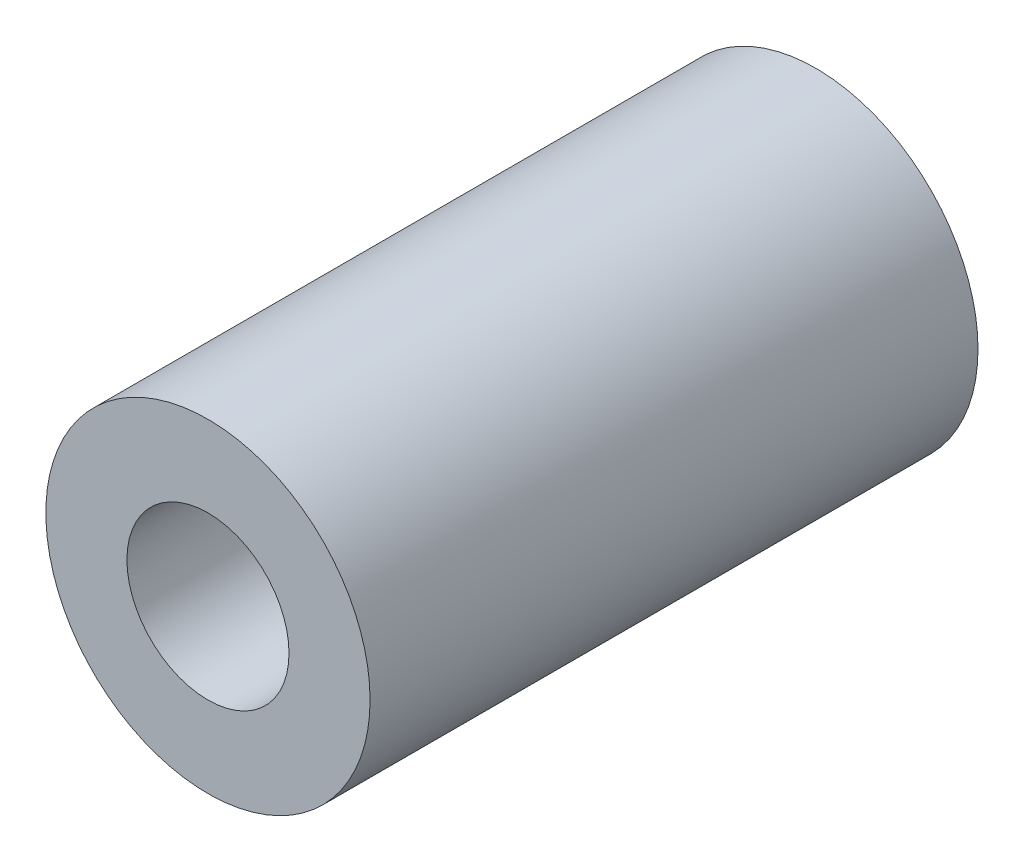
from build123d import *

# Parameters (mm, degrees)
SKETCH1_R           = 8
SKETCH1_R_2         = 4
BOSS_EXTRUDE1_DEPTH = 30


with BuildPart() as part:
    # Sketch1 → Boss-Extrude1 (new body)
    with BuildSketch(Plane.XY):
        Circle(SKETCH1_R)
        Circle(SKETCH1_R_2, mode=Mode.SUBTRACT)
    extrude(amount=BOSS_EXTRUDE1_DEPTH)


solid = part.part
